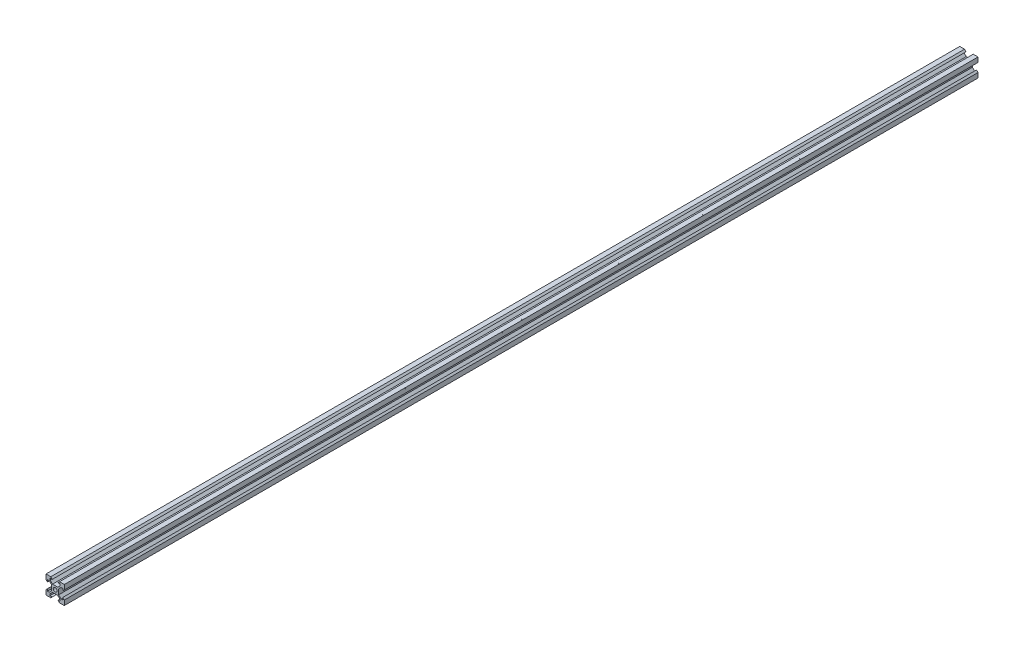
from build123d import *

# Parameters (mm, degrees)
SKETCH1_R           = 2.1
BOSS_EXTRUDE1_DEPTH = 1000


with BuildPart() as part:
    # Sketch1 → Boss-Extrude1 (new body)
    with BuildSketch(Plane.XY):
        Polygon((2.834320347, 3.893970342), (5.5, 6.558849663), (5.5, 8.349069506), (3.1, 8.349069506), (4.75, 9.998574117), (10, 9.998574117), (10, 4.746997406), (8.35, 3.097492795), (8.350720674, 5.497492687), (6.560500912, 5.498030255), (3.894821259, 2.833150935), (3.894821259, -2.833150935), (6.560500912, -5.498030255), (8.350720674, -5.497492687), (8.35, -3.097492795), (10, -4.746997406), (10, -9.998574117), (4.75, -9.998574117), (3.1, -8.349069506), (5.5, -8.349069506), (5.5, -6.558849663), (2.834320347, -3.893970342), (-2.834320347, -3.893970342), (-5.5, -6.558849663), (-5.5, -8.349069506), (-3.1, -8.349069506), (-4.75, -9.998574117), (-10, -9.998574117), (-10, -4.746997406), (-8.35, -3.097492795), (-8.350720674, -5.497492687), (-6.560500912, -5.498030255), (-3.894821259, -2.833150935), (-3.894821259, 2.833150935), (-6.560500912, 5.498030255), (-8.350720674, 5.497492687), (-8.35, 3.097492795), (-10, 4.746997406), (-10, 9.998574117), (-4.75, 9.998574117), (-3.1, 8.349069506), (-5.5, 8.349069506), (-5.5, 6.558849663), (-2.834320347, 3.893970342), align=None)
        Circle(SKETCH1_R, mode=Mode.SUBTRACT)
    extrude(amount=BOSS_EXTRUDE1_DEPTH)


solid = part.part
